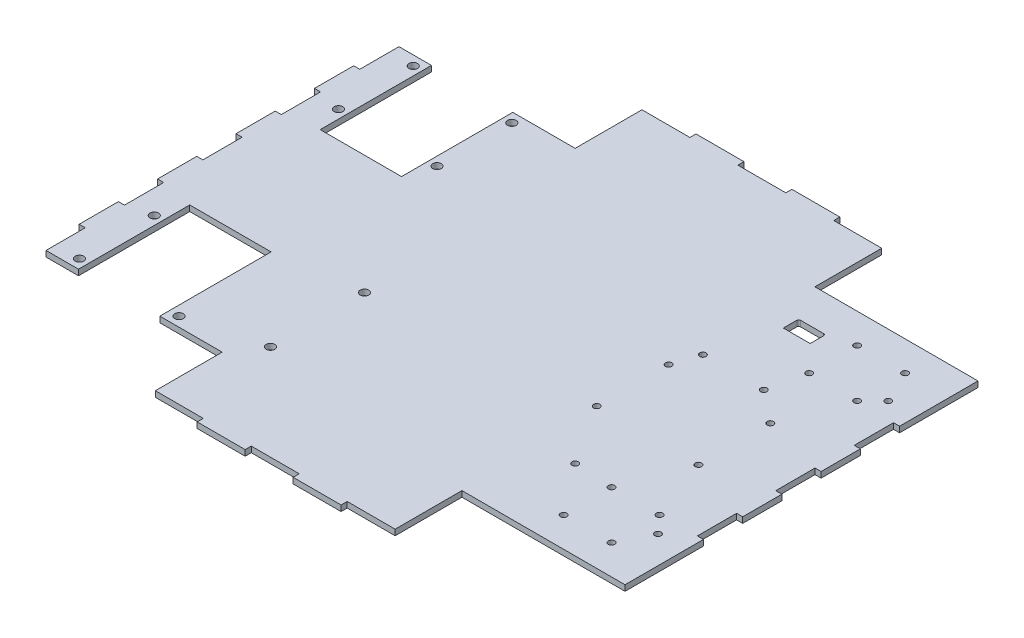
from build123d import *

# Parameters (mm, degrees)
SKETCH1_R           = 1.65
SKETCH1_R_2         = 2.25
BOSS_EXTRUDE1_DEPTH = 3


with BuildPart() as part:
    # Sketch1 → Boss-Extrude1 (new body)
    with BuildSketch(Plane(origin=(0, 0, 0), x_dir=(1, 0, 0), z_dir=(0, 1, 0))):
        Polygon((152.5, 92), (67.5, 92), (67.5, 126.825), (42.5, 126.825), (42.5, 130), (17.5, 130), (17.5, 126.825), (-7.5, 126.825), (-7.5, 130), (-32.5, 130), (-32.5, 126.825), (-57.5, 126.825), (-57.5, 92), (-90.0007, 92), (-90.0007, 34), (-132.3969, 34), (-132.3969, 92), (-149.325, 92), (-149.325, 71.555555556), (-152.5, 71.555555556), (-152.5, 51.111111111), (-149.325, 51.111111111), (-149.325, 30.666666667), (-152.5, 30.666666667), (-152.5, 10.222222222), (-149.325, 10.222222222), (-149.325, -10.222222222), (-152.5, -10.222222222), (-152.5, -30.666666667), (-149.325, -30.666666667), (-149.325, -51.111111111), (-152.5, -51.111111111), (-152.5, -71.555555556), (-149.325, -71.555555556), (-149.325, -92), (-132.3969, -92), (-132.3969, -34), (-90.0007, -34), (-90.0007, -92), (-57.5, -92), (-57.5, -126.825), (-32.5, -126.825), (-32.5, -130), (-7.5, -130), (-7.5, -126.825), (17.5, -126.825), (17.5, -130), (42.5, -130), (42.5, -126.825), (67.5, -126.825), (67.5, -92), (152.5, -92), (152.5, -51.111111111), (149.325, -51.111111111), (149.325, -30.666666667), (152.5, -30.666666667), (152.5, -10.222222222), (149.325, -10.222222222), (149.325, 10.222222222), (152.5, 10.222222222), (152.5, 30.666666667), (149.325, 30.666666667), (149.325, 51.111111111), (152.5, 51.111111111), align=None)
        with Locations((105, 76.5)):
            Circle(SKETCH1_R, mode=Mode.SUBTRACT)
        with Locations((130, 76.5)):
            Circle(SKETCH1_R, mode=Mode.SUBTRACT)
        with Locations((-136.8894, -87)):
            Circle(SKETCH1_R_2, mode=Mode.SUBTRACT)
        with Locations((-85.0006, -87)):
            Circle(SKETCH1_R_2, mode=Mode.SUBTRACT)
        with Locations((-47.3083, -77)):
            Circle(SKETCH1_R_2, mode=Mode.SUBTRACT)
        with Locations((-136.8894, -48)):
            Circle(SKETCH1_R_2, mode=Mode.SUBTRACT)
        with Locations((-47.3083, -28)):
            Circle(SKETCH1_R_2, mode=Mode.SUBTRACT)
        with Locations((105, -76.5)):
            Circle(SKETCH1_R, mode=Mode.SUBTRACT)
        with Locations((130, -76.5)):
            Circle(SKETCH1_R, mode=Mode.SUBTRACT)
        with Locations((84.82, -50.289)):
            Circle(SKETCH1_R, mode=Mode.SUBTRACT)
        with Locations((105, -51.5)):
            Circle(SKETCH1_R, mode=Mode.SUBTRACT)
        with Locations((130, -51.5)):
            Circle(SKETCH1_R, mode=Mode.SUBTRACT)
        with Locations((138.16, -60.452)):
            Circle(SKETCH1_R, mode=Mode.SUBTRACT)
        with Locations((64.5, -18.75)):
            Circle(SKETCH1_R, mode=Mode.SUBTRACT)
        with Locations((117.5, -18.75)):
            Circle(SKETCH1_R, mode=Mode.SUBTRACT)
        with Locations((-136.88945, 48)):
            Circle(SKETCH1_R_2, mode=Mode.SUBTRACT)
        with Locations((-85.50815, 48)):
            Circle(SKETCH1_R_2, mode=Mode.SUBTRACT)
        with Locations((-136.88945, 87)):
            Circle(SKETCH1_R_2, mode=Mode.SUBTRACT)
        with Locations((-85.50815, 87)):
            Circle(SKETCH1_R_2, mode=Mode.SUBTRACT)
        with Locations((64.5, 18.75)):
            Circle(SKETCH1_R, mode=Mode.SUBTRACT)
        with Locations((68.945, 32.131)):
            Circle(SKETCH1_R, mode=Mode.SUBTRACT)
        with Locations((100.695, 32.131)):
            Circle(SKETCH1_R, mode=Mode.SUBTRACT)
        with Locations((117.5, 18.75)):
            Circle(SKETCH1_R, mode=Mode.SUBTRACT)
        with Locations((105, 51.5)):
            Circle(SKETCH1_R, mode=Mode.SUBTRACT)
        with Locations((130, 51.5)):
            Circle(SKETCH1_R, mode=Mode.SUBTRACT)
        with Locations((138.16, 59.563)):
            Circle(SKETCH1_R, mode=Mode.SUBTRACT)
        with BuildLine():
            Line((91.88, 65.143), (77.88, 65.143))
            Line((77.88, 65.143), (77.88, 72.143))
            ThreePointArc((77.88, 72.143), (78.172893219, 72.850106781), (78.88, 73.143))
            Line((78.88, 73.143), (90.88, 73.143))
            ThreePointArc((90.88, 73.143), (91.587106781, 72.850106781), (91.88, 72.143))
            Line((91.88, 72.143), (91.88, 65.143))
        make_face(mode=Mode.SUBTRACT)
    extrude(amount=BOSS_EXTRUDE1_DEPTH)


solid = part.part
